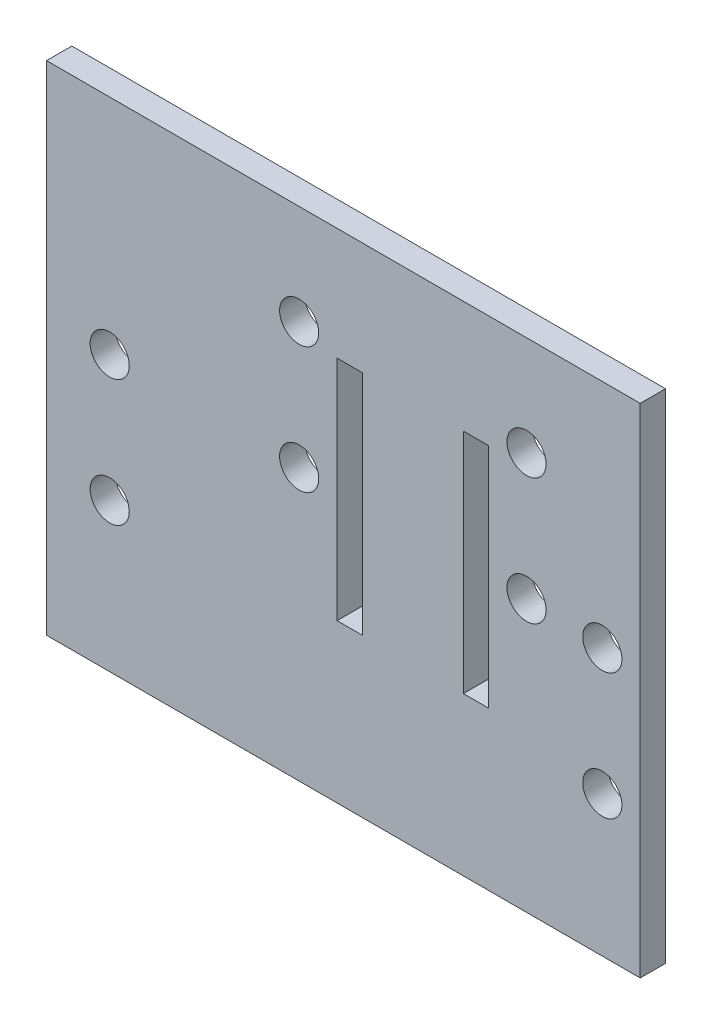
from build123d import *

# Parameters (mm, degrees)
SKETCH_1_W      = 47
SKETCH_1_H      = 39.4
SKETCH_1_R      = 1.55
SKETCH_1_W_2    = 2
SKETCH_1_H_2    = 18
EXTRUDE_1_DEPTH = 2


with BuildPart() as part:
    # 草图1 → 凸台-拉伸1 (new body)
    with BuildSketch(Plane.XY):
        Rectangle(SKETCH_1_W, SKETCH_1_H)
        with Locations((20.5, 1.43)):
            Circle(SKETCH_1_R, mode=Mode.SUBTRACT)
        with Locations((20.5, -8.57)):
            Circle(SKETCH_1_R, mode=Mode.SUBTRACT)
        with Locations((-18.5, 2.05)):
            Circle(SKETCH_1_R, mode=Mode.SUBTRACT)
        with Locations((-18.5, -7.95)):
            Circle(SKETCH_1_R, mode=Mode.SUBTRACT)
        with Locations((-3.499999601, 11.8)):
            Circle(SKETCH_1_R, mode=Mode.SUBTRACT)
        with Locations((-3.5, 1.8)):
            Circle(SKETCH_1_R, mode=Mode.SUBTRACT)
        with Locations((14.5, 11.8)):
            Circle(SKETCH_1_R, mode=Mode.SUBTRACT)
        with Locations((14.5, 1.8)):
            Circle(SKETCH_1_R, mode=Mode.SUBTRACT)
        with Locations((10.5, 1.8)):
            Rectangle(SKETCH_1_W_2, SKETCH_1_H_2, mode=Mode.SUBTRACT)
        with Locations((0.5, 1.8)):
            Rectangle(SKETCH_1_W_2, SKETCH_1_H_2, mode=Mode.SUBTRACT)
    extrude(amount=EXTRUDE_1_DEPTH)


solid = part.part
